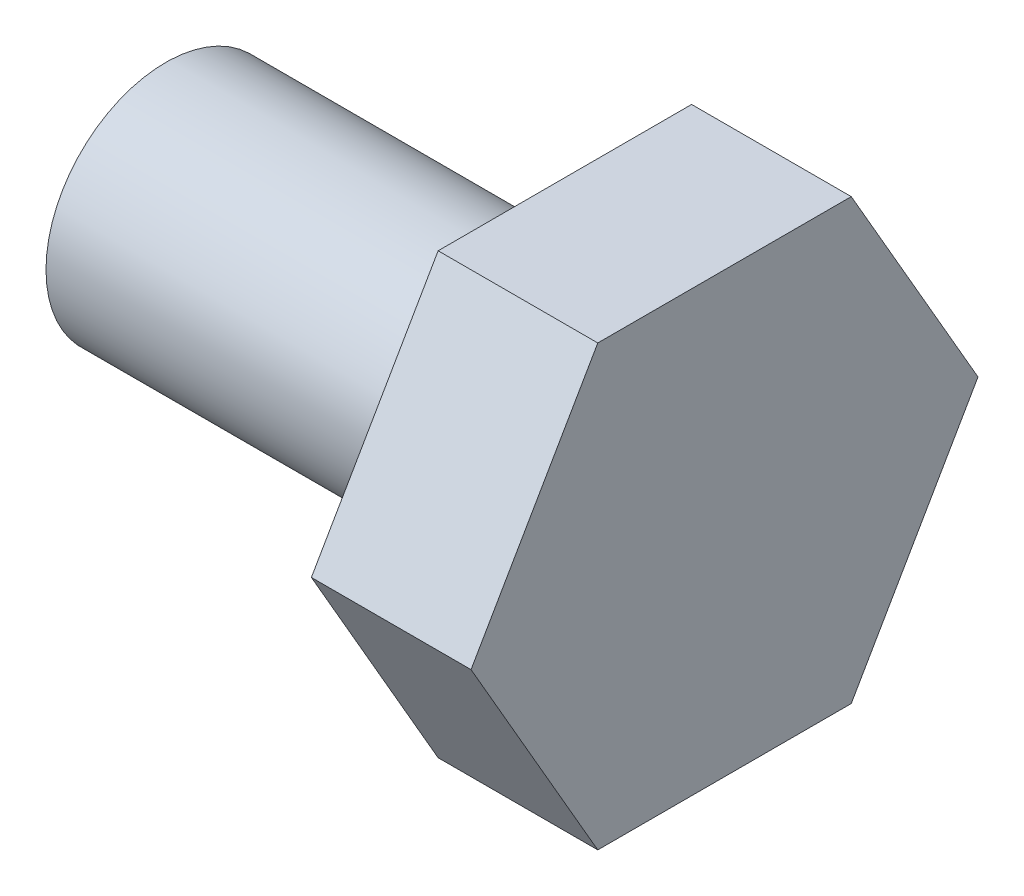
from build123d import *

# Parameters (mm, degrees)
SKETCH1_W           = 5
SKETCH1_H           = 1.5
BOSS_EXTRUDE1_DEPTH = 2


with BuildPart() as part:
    # Sketch1 → Revolve1 (revolve)
    with BuildSketch(Plane.XY):
        with Locations((0, 0.75)):
            Rectangle(SKETCH1_W, SKETCH1_H)
    revolve(axis=Axis((-16.166606446, 0, 0), (1, 0, 0)))

    # Sketch2 → Boss-Extrude1 (add)
    with BuildSketch(Plane(origin=(2.5, 0, 0), x_dir=(0, 0, -1), z_dir=(1, 0, 0))):
        Polygon((1.58771324, 2.75), (-1.58771324, 2.75), (-3.175426481, 0), (-1.58771324, -2.75), (1.58771324, -2.75), (3.175426481, 0), align=None)
    extrude(amount=BOSS_EXTRUDE1_DEPTH)


solid = part.part
